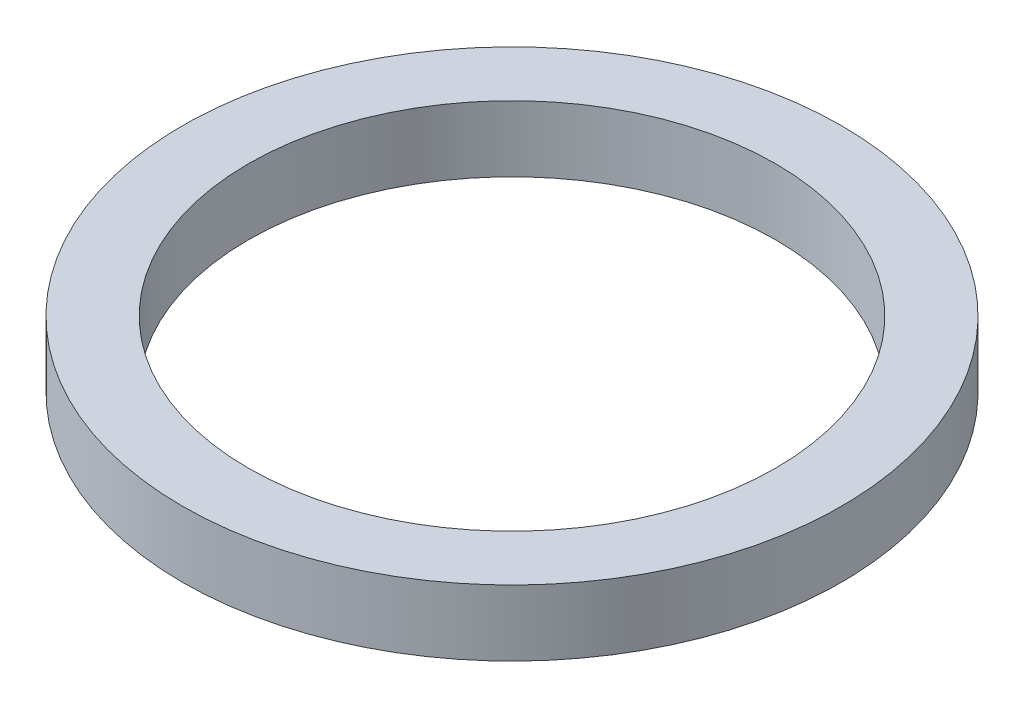
from build123d import *

# Parameters (mm, degrees)
SKETCH1_R           = 20
SKETCH1_R_2         = 16
BOSS_EXTRUDE1_DEPTH = 4


with BuildPart() as part:
    # Sketch1 → Boss-Extrude1 (new body)
    with BuildSketch(Plane(origin=(0, 0, 0), x_dir=(1, 0, 0), z_dir=(0, 1, 0))):
        Circle(SKETCH1_R)
        Circle(SKETCH1_R_2, mode=Mode.SUBTRACT)
    extrude(amount=BOSS_EXTRUDE1_DEPTH)


solid = part.part
